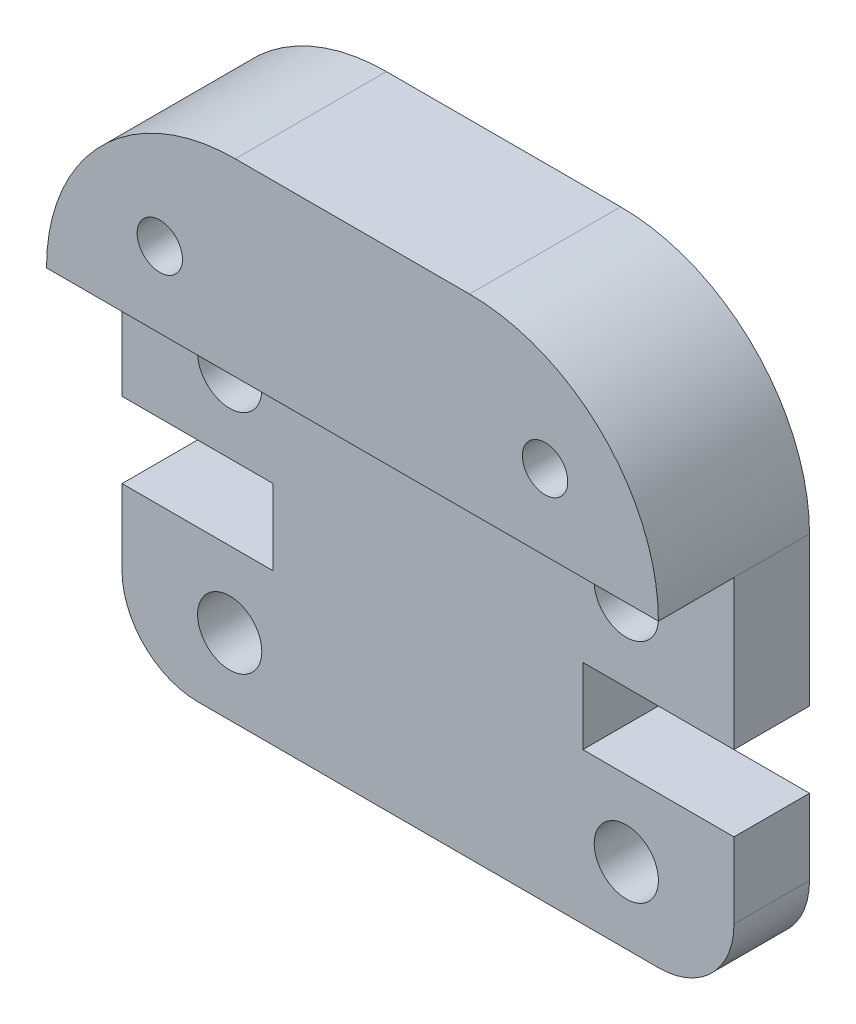
from build123d import *

# Parameters (mm, degrees)
SKETCH2_R           = 0.85
SKETCH2_R_2         = 0.6
BOSS_EXTRUDE1_DEPTH = 4
SKETCH3_W           = 16.2
SKETCH3_H           = 9.945
CUT_EXTRUDE2_DEPTH  = 2


with BuildPart() as part:
    # Sketch2 → Boss-Extrude1 (new body)
    with BuildSketch(Plane.XY):
        with BuildLine():
            Line((0, 9.945), (0, 6))
            Line((0, 6), (4, 6))
            Line((4, 6), (4, 4))
            Line((4, 4), (0, 4))
            Line((0, 4), (0, 2))
            ThreePointArc((0, 2), (0.585786438, 0.585786438), (2, 0))
            Line((2, 0), (14.2, 0))
            ThreePointArc((14.2, 0), (15.614213562, 0.585786438), (16.2, 2))
            Line((16.2, 2), (16.2, 4))
            Line((16.2, 4), (12.2, 4))
            Line((12.2, 4), (12.2, 6))
            Line((12.2, 6), (16.2, 6))
            Line((16.2, 6), (16.2, 9.945))
            ThreePointArc((16.2, 9.945), (14.735533906, 13.480533906), (11.2, 14.945))
            Line((11.2, 14.945), (5, 14.945))
            ThreePointArc((5, 14.945), (1.464466094, 13.480533906), (0, 9.945))
        make_face()
        with Locations((13.35, 8)):
            Circle(SKETCH2_R, mode=Mode.SUBTRACT)
        with Locations((13.35, 2)):
            Circle(SKETCH2_R, mode=Mode.SUBTRACT)
        with Locations((13.2, 11.942)):
            Circle(SKETCH2_R_2, mode=Mode.SUBTRACT)
        with Locations((3, 11.942)):
            Circle(SKETCH2_R_2, mode=Mode.SUBTRACT)
        with Locations((2.85, 2)):
            Circle(SKETCH2_R, mode=Mode.SUBTRACT)
        with Locations((2.85, 8)):
            Circle(SKETCH2_R, mode=Mode.SUBTRACT)
    extrude(amount=BOSS_EXTRUDE1_DEPTH)

    # Sketch3 → Cut-Extrude2 (cut)
    with BuildSketch(Plane(origin=(0, 0, 4), x_dir=(-1, 0, 0), z_dir=(0, 0, -1))):
        with Locations((-8.1, 4.9725)):
            Rectangle(SKETCH3_W, SKETCH3_H)
    extrude(amount=CUT_EXTRUDE2_DEPTH, mode=Mode.SUBTRACT)


solid = part.part
